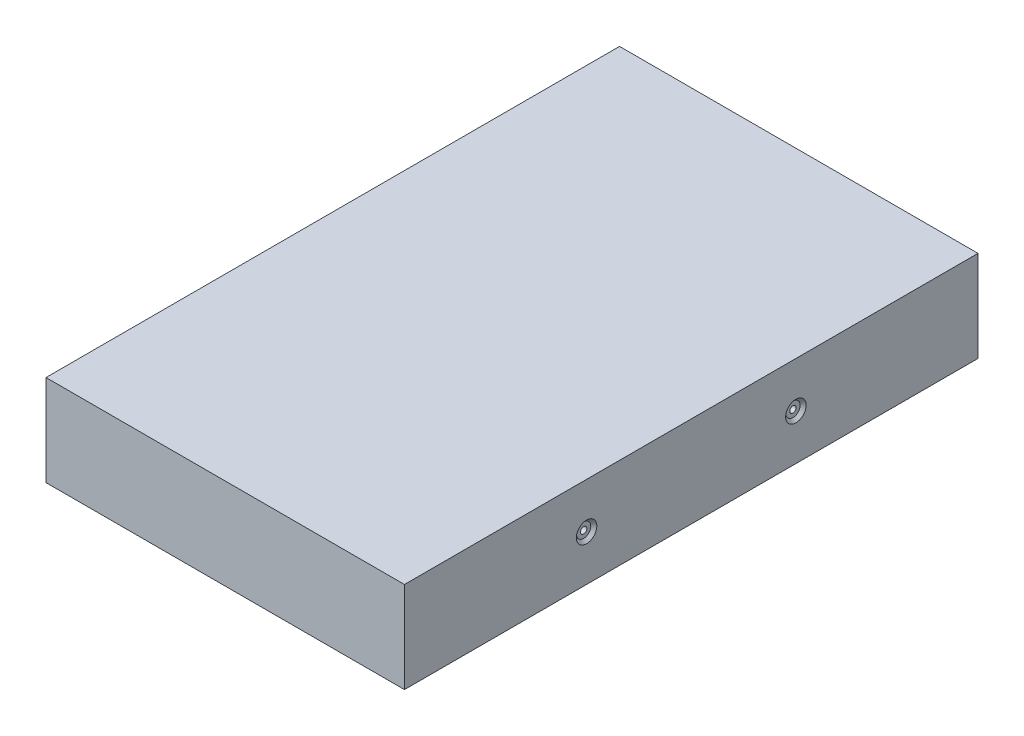
from build123d import *

# Parameters (mm, degrees)
SKETCH1_W                                   = 100
SKETCH1_H                                   = 160
BOSS_EXTRUDE1_DEPTH                         = 25.4
CBORE_FOR_0_BINDING_HEAD_MACHINE_SC_2_COUNT = 2
CBORE_FOR_0_BINDING_HEAD_MACHINE_SC_2_PITCH = 58.4


with BuildPart() as part:
    # Sketch1 → Boss-Extrude1 (new body)
    with BuildSketch(Plane(origin=(0, 0, 0), x_dir=(1, 0, 0), z_dir=(0, 1, 0))):
        Rectangle(SKETCH1_W, SKETCH1_H)
    extrude(amount=BOSS_EXTRUDE1_DEPTH)

    # Sketch3 → CBORE for #0 Binding Head Machine Screw1 (revolve, cut)
    with BuildSketch(Plane(origin=(50, 12.7, 29.2), x_dir=(0, 0, -1), z_dir=(0, 1, 0))):
        Polygon((0, 0), (0, 30.53416509), (0.889, 30), (0.889, 0.8128), (1.98501, 0.8128), (1.98501, 0.87249), (2.8575, 0), align=None)
    cbore_for_0_binding_head_machine_screw1 = revolve(axis=Axis((56.35, 12.7, 29.2), (-1, 0, 0)), mode=Mode.SUBTRACT)

    # CBORE for _0 Binding Head Machine Sc 2: CBORE for #0 Binding Head Machine Screw1 ×2
    with Locations(*[(0, 0, -i * CBORE_FOR_0_BINDING_HEAD_MACHINE_SC_2_PITCH) for i in range(1, CBORE_FOR_0_BINDING_HEAD_MACHINE_SC_2_COUNT)]):
        add(cbore_for_0_binding_head_machine_screw1, mode=Mode.SUBTRACT)


solid = part.part
